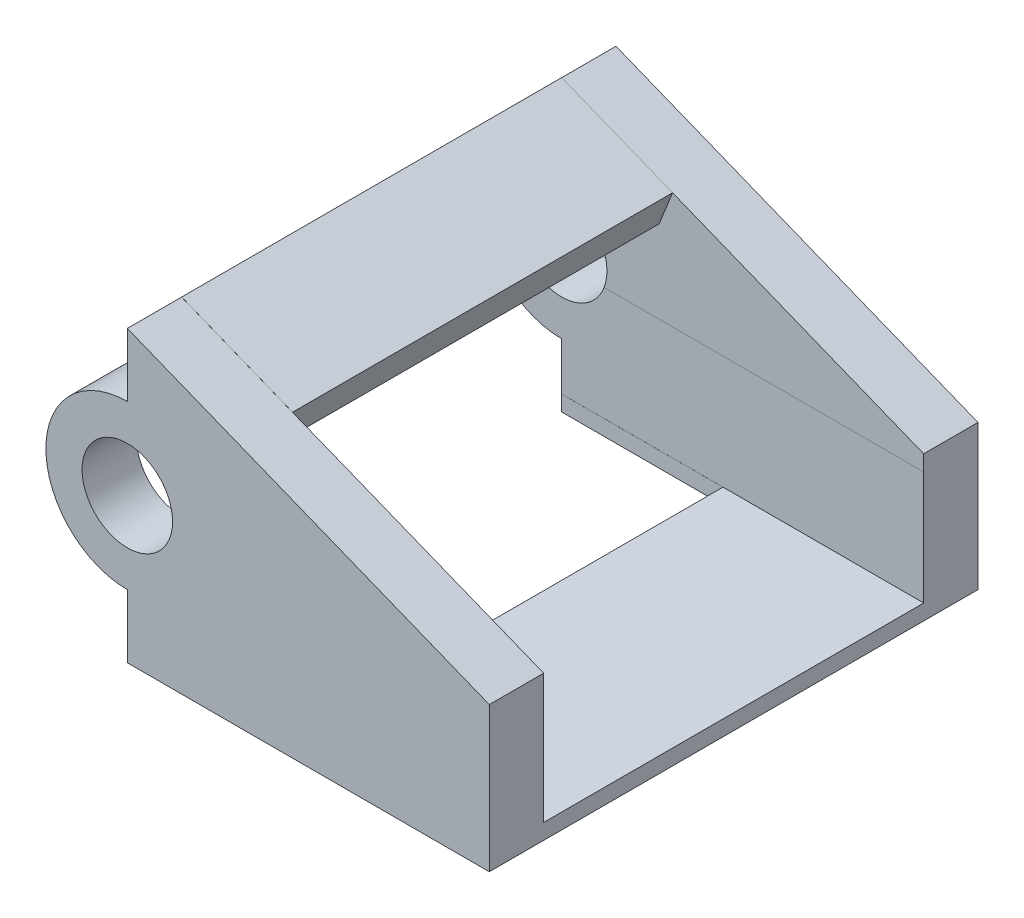
from build123d import *

# Parameters (mm, degrees)
EXTRUDE_2_DEPTH      = 27
CUT_EXTRUDE_1_DEPTH  = 30
CUT_EXTRUDE_3_DEPTH  = 30
SKETCH_8_W           = 8.910998672
SKETCH_8_H           = 15
CUT_EXTRUDE_4_DEPTH  = 30
SKETCH_38_W          = 5.996496197
SKETCH_38_H          = 7.141479878
CUT_EXTRUDE_5_DEPTH  = 40
SKETCH_41_W          = 6
SKETCH_41_H          = 16.93537555
CUT_EXTRUDE_6_DEPTH  = 40
SKETCH_43_W          = 8.910998672
SKETCH_43_H          = 6
CUT_EXTRUDE_7_DEPTH  = 40
SKETCH_36_R          = 2.5
CUT_EXTRUDE_8_DEPTH  = 40
SKETCH_45_W          = 9.597439288
SKETCH_45_H          = 20.996496197
EXTRUDE_8_DEPTH      = 2
CUT_EXTRUDE_10_DEPTH = 25
SKETCH_49_W          = 3
SKETCH_49_H          = 20.996496197
CUT_EXTRUDE_11_DEPTH = 10


with BuildPart() as part:
    # 草图1 → 凸台-拉伸2 (new body)
    with BuildSketch(Plane.XY):
        with BuildLine():
            Line((-8.910998672, 11.111238711), (11.089001328, 3.111238711))
            Line((11.089001328, 3.111238711), (11.089001328, -4.888761289))
            Line((11.089001328, -4.888761289), (-8.910998672, -4.888761289))
            Line((-8.910998672, -4.888761289), (-8.910998672, -3.888761289))
            Line((-8.910998672, -3.888761289), (-8.910998672, -1.388761289))
            ThreePointArc((-8.910998672, -1.388761289), (-13.410998672, 3.111238711), (-8.910998672, 7.611238711))
            Line((-8.910998672, 7.611238711), (-8.910998672, 10.111238711))
            Line((-8.910998672, 10.111238711), (-8.910998672, 11.111238711))
        make_face()
    extrude(amount=EXTRUDE_2_DEPTH)

    # 草图19 → 切除-拉伸-薄壁1 (cut)
    with BuildSketch(Plane(origin=(11.089001328, 0, 0), x_dir=(0, 0, -1), z_dir=(1, 0, 0))):
        Polygon((-18, -4.030241167), (-18, 12.241944183), (-3, 12.241944183), (-3, 2.241944183), (-8, 2.241944183), (-8, -4.030241167), align=None)
    extrude(amount=-CUT_EXTRUDE_1_DEPTH, mode=Mode.SUBTRACT)

    # 草图27 → 切除-拉伸3 (cut)
    with BuildSketch(Plane(origin=(11.089001328, 0, 0), x_dir=(0, 0, -1), z_dir=(1, 0, 0))):
        Polygon((-8, -4.030241167), (-2.998694363, -4.030241167), (-3, 2.241944183), (-8, 2.241944183), align=None)
    extrude(amount=-CUT_EXTRUDE_3_DEPTH, mode=Mode.SUBTRACT)

    # 草图8 → 切除-拉伸4 (cut)
    with BuildSketch(Plane(origin=(0, -4.888761289, 0), x_dir=(-1, 0, 0), z_dir=(0, -1, 0))):
        with Locations((4.455499336, -10.5)):
            Rectangle(SKETCH_8_W, SKETCH_8_H)
    extrude(amount=-CUT_EXTRUDE_4_DEPTH, mode=Mode.SUBTRACT)

    # 草图38 → 切除-拉伸5 (cut)
    with BuildSketch(Plane(origin=(11.089001328, 0, 0), x_dir=(0, 0, -1), z_dir=(1, 0, 0))):
        with Locations((-20.998248098, -0.459501228)):
            Rectangle(SKETCH_38_W, SKETCH_38_H)
    extrude(amount=-CUT_EXTRUDE_5_DEPTH, mode=Mode.SUBTRACT)

    # 草图41 → 切除-拉伸6 (cut)
    with BuildSketch(Plane(origin=(21.089001328, 0, 0), x_dir=(0, 0, -1), z_dir=(1, 0, 0))):
        with Locations((-20.996496197, 4.437446608)):
            Rectangle(SKETCH_41_W, SKETCH_41_H)
    extrude(amount=-CUT_EXTRUDE_6_DEPTH, mode=Mode.SUBTRACT)

    # 草图43 → 切除-拉伸7 (cut)
    with BuildSketch(Plane.XZ.offset(4.888761289)):
        with Locations((-4.455499336, 21)):
            Rectangle(SKETCH_43_W, SKETCH_43_H)
    extrude(amount=-CUT_EXTRUDE_7_DEPTH, mode=Mode.SUBTRACT)

    # 草图36 → 切除-拉伸8 (cut)
    with BuildSketch(Plane(origin=(0, 0, 0), x_dir=(-1, 0, 0), z_dir=(0, 0, -1))):
        with Locations((8.910998672, 3.111238711)):
            Circle(SKETCH_36_R)
    extrude(amount=-CUT_EXTRUDE_8_DEPTH, mode=Mode.SUBTRACT)


with BuildPart() as body_2:
    # 草图45 → 凸台-拉伸8 (new body)
    with BuildSketch(Plane(origin=(2.602358359, 6.505895899, 0), x_dir=(0.928476691, -0.371390676, 0), z_dir=(0.371390676, 0.928476691, 0))):
        with Locations((-7.601545375, -13.498248099)):
            Rectangle(SKETCH_45_W, SKETCH_45_H)
    extrude(amount=-EXTRUDE_8_DEPTH)

    # 草图47 → 切除-拉伸10 (cut)
    with BuildSketch(Plane(origin=(0, 0, 3), x_dir=(-1, 0, 0), z_dir=(0, 0, -1))):
        Polygon((8.910998672, 11.111238711), (8.910998672, 8.957172788), (9.653780025, 9.254285329), align=None)
    extrude(amount=-CUT_EXTRUDE_10_DEPTH, mode=Mode.SUBTRACT)

    # 草图49 → 切除-拉伸11 (cut)
    with BuildSketch(Plane(origin=(2.602358359, 6.505895899, 0), x_dir=(0.928476691, -0.371390676, 0), z_dir=(0.371390676, 0.928476691, 0))):
        with Locations((-4.302825731, -13.498248099)):
            Rectangle(SKETCH_49_W, SKETCH_49_H)
    extrude(amount=-CUT_EXTRUDE_11_DEPTH, mode=Mode.SUBTRACT)


solid = Compound([part.part, body_2.part])
